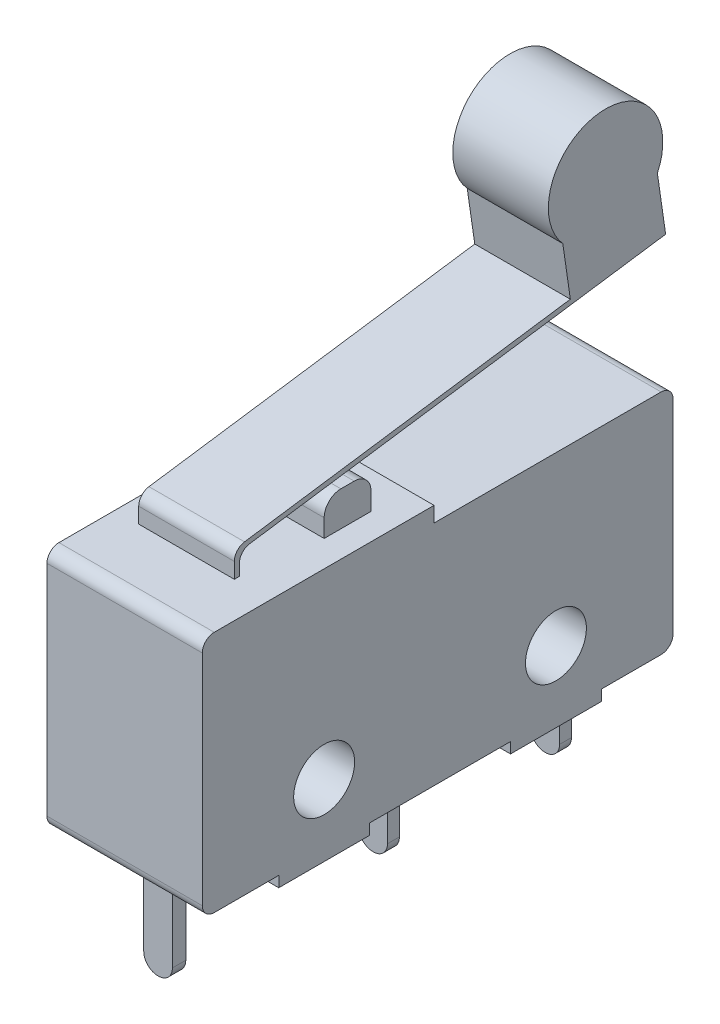
from build123d import *

# Parameters (mm, degrees)
SKETCH1_R           = 1.275
BOSS_EXTRUDE1_DEPTH = 6.5
SKETCH2_W           = 3.53
SKETCH2_H           = 1.96
BOSS_EXTRUDE2_DEPTH = 1.45
FILLET1_R           = 0.7
SKETCH3_W           = 3.2
SKETCH3_H           = 0.56
SKETCH3_H_2         = 0.5
BOSS_EXTRUDE3_DEPTH = 0.9
SKETCH4_W           = 1.2
SKETCH4_H           = 0.56
SKETCH4_H_2         = 0.5
BOSS_EXTRUDE4_DEPTH = 3.47
FILLET2_R           = 0.59
EXTRUDE_START       = -1.5
EXTRUDE_1_DEPTH     = 4
FILLET_1_R          = 0.5


with BuildPart() as part:
    # Sketch1 → Boss-Extrude1 (new body)
    with BuildSketch(Plane(origin=(0, 0, 0), x_dir=(0, 0, -1), z_dir=(1, 0, 0))):
        with BuildLine():
            Line((-37.373122581, 0), (-34.673122581, 0))
            Line((-34.673122581, 0), (-34.673122581, -0.45))
            Line((-34.673122581, -0.45), (-30.873122581, -0.45))
            Line((-30.873122581, -0.45), (-30.873122581, 0))
            Line((-30.873122581, 0), (-24.973122581, 0))
            Line((-24.973122581, 0), (-24.973122581, -0.45))
            Line((-24.973122581, -0.45), (-21.173122581, -0.45))
            Line((-21.173122581, -0.45), (-21.173122581, 0))
            Line((-21.173122581, 0), (-18.673122581, 0))
            ThreePointArc((-18.673122581, 0), (-18.31956919, 0.146446609), (-18.173122581, 0.5))
            Line((-18.173122581, 0.5), (-18.173122581, 9.02))
            ThreePointArc((-18.173122581, 9.02), (-18.31956919, 9.373553391), (-18.673122581, 9.52))
            Line((-18.673122581, 9.52), (-28.173122581, 9.52))
            Line((-28.173122581, 9.52), (-28.173122581, 10.16))
            Line((-28.173122581, 10.16), (-37.373122581, 10.16))
            ThreePointArc((-37.373122581, 10.16), (-37.726675972, 10.013553391), (-37.873122581, 9.66))
            Line((-37.873122581, 9.66), (-37.873122581, 0.5))
            ThreePointArc((-37.873122581, 0.5), (-37.726675972, 0.146446609), (-37.373122581, 0))
        make_face()
        with Locations((-32.773122581, 2.525)):
            Circle(SKETCH1_R, mode=Mode.SUBTRACT)
        with Locations((-23.073122581, 2.525)):
            Circle(SKETCH1_R, mode=Mode.SUBTRACT)
    extrude(amount=BOSS_EXTRUDE1_DEPTH)

    # Sketch2 → Boss-Extrude2 (add)
    with BuildSketch(Plane(origin=(0, 10.16, 0), x_dir=(1, 0, 0), z_dir=(0, 1, 0))):
        with Locations((3.635, -30.693122581)):
            Rectangle(SKETCH2_W, SKETCH2_H)
    extrude(amount=BOSS_EXTRUDE2_DEPTH)

    # Fillet1
    fillet1_edges = [part.edges().sort_by_distance(p)[0] for p in [
        (3.635, 11.61, 31.673122581),
        (3.635, 11.61, 29.713122581),
    ]]
    fillet(fillet1_edges, radius=FILLET1_R)

    # Sketch3 → Boss-Extrude3 (add)
    with BuildSketch(Plane(origin=(0, 0, 0), x_dir=(-1, 0, 0), z_dir=(0, -1, 0))):
        with Locations((-3.25, -36.193122581)):
            Rectangle(SKETCH3_W, SKETCH3_H)
        with Locations((-3.25, -27.223122581)):
            Rectangle(SKETCH3_W, SKETCH3_H_2)
        with Locations((-3.25, -20.023122581)):
            Rectangle(SKETCH3_W, SKETCH3_H_2)
    extrude(amount=BOSS_EXTRUDE3_DEPTH)

    # Sketch4 → Boss-Extrude4 (add)
    with BuildSketch(Plane(origin=(0, -0.9, 0), x_dir=(-1, 0, 0), z_dir=(0, -1, 0))):
        with Locations((-3.25, -36.193122581)):
            Rectangle(SKETCH4_W, SKETCH4_H)
        with Locations((-3.25, -27.223122581)):
            Rectangle(SKETCH4_W, SKETCH4_H_2)
        with Locations((-3.25, -20.023122581)):
            Rectangle(SKETCH4_W, SKETCH4_H_2)
    extrude(amount=BOSS_EXTRUDE4_DEPTH)

    # Fillet2
    fillet2_edges = [part.edges().sort_by_distance(p)[0] for p in [
        (2.65, -4.37, 36.193122581),
        (3.85, -4.37, 36.193122581),
        (2.65, -4.37, 27.223122581),
        (3.85, -4.37, 27.223122581),
        (3.85, -4.37, 20.023122581),
        (2.65, -4.37, 20.023122581),
    ]]
    fillet(fillet2_edges, radius=FILLET2_R)

    # Эскиз1 → Бобышка-Вытянуть1 (add)
    with BuildSketch(Plane(origin=(6.5, 0, 0), x_dir=(0, 0, -1), z_dir=(1, 0, 0)).offset(EXTRUDE_START)):
        with BuildLine():
            Line((-35.033122581, 10.16), (-34.820611294, 10.16))
            Line((-34.820611294, 10.16), (-34.820611294, 11.065475419))
            Line((-34.820611294, 11.065475419), (-16.983122581, 13.639958326))
            Line((-16.983122581, 13.639958326), (-17.327590515, 16.026629013))
            ThreePointArc((-17.327590515, 16.026629013), (-19.152479599, 14.674662016), (-21.2856409, 15.454186098))
            Line((-21.2856409, 15.454186098), (-20.970513986, 13.279774136))
            Line((-20.970513986, 13.279774136), (-35.033122581, 11.241748905))
            Line((-35.033122581, 11.241748905), (-35.033122581, 10.16))
        make_face()
        with BuildLine():
            ThreePointArc((-21.2856409, 15.454186098), (-19.152479599, 14.674662016), (-17.327590515, 16.026629013))
            Line((-17.327590515, 16.026629013), (-17.515806862, 17.330699412))
            ThreePointArc((-17.515806862, 17.330699412), (-19.781572094, 19.024405415), (-21.474617523, 16.75814654))
            Line((-21.474617523, 16.75814654), (-21.2856409, 15.454186098))
        make_face()
        with BuildLine():
            Line((-17.515806862, 17.330699412), (-17.327590515, 16.026629013))
            ThreePointArc((-17.327590515, 16.026629013), (-17.157809946, 16.523285896), (-17.100295646, 17.045))
            ThreePointArc((-17.100295646, 17.045), (-17.801774905, 18.738520741), (-19.495295646, 19.44))
            ThreePointArc((-19.495295646, 19.44), (-21.680018087, 18.026332182), (-21.2856409, 15.454186098))
            Line((-21.2856409, 15.454186098), (-21.474617523, 16.75814654))
            ThreePointArc((-21.474617523, 16.75814654), (-19.781572094, 19.024405415), (-17.515806862, 17.330699412))
        make_face()
    extrude(amount=-EXTRUDE_1_DEPTH)

    # Скругление1
    fillet_1_edges = [part.edges().sort_by_distance(p)[0] for p in [
        (3, 11.065475419, 34.820611294),
        (3, 11.241748905, 35.033122581),
    ]]
    fillet(fillet_1_edges, radius=FILLET_1_R)


solid = part.part
